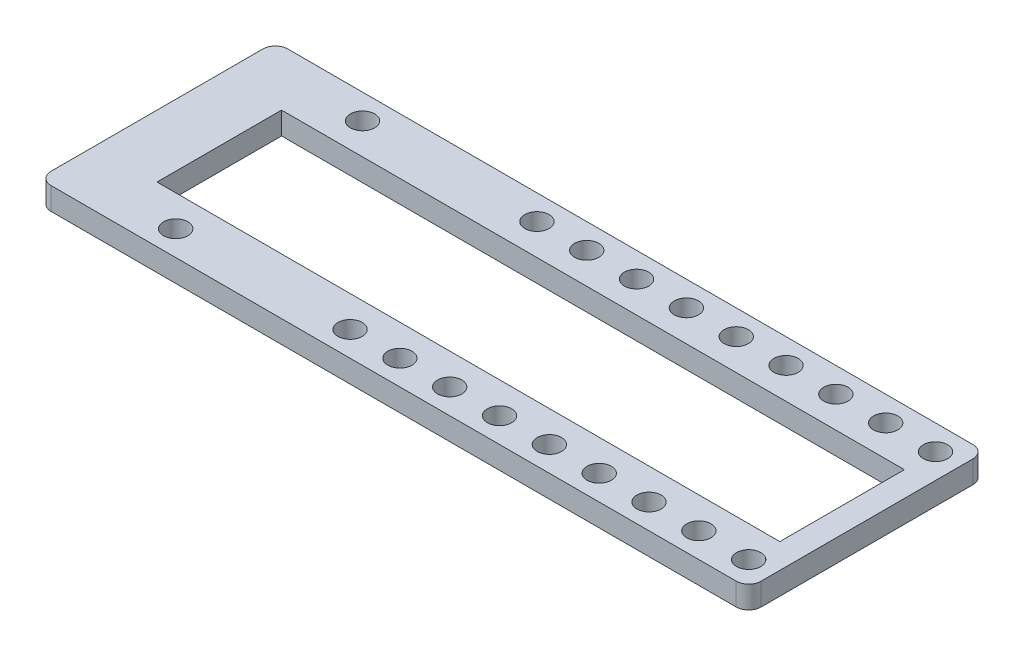
from build123d import *

# Parameters (mm, degrees)
BOSS_EXTRUDE1_DEPTH = 3.6
SKETCH2_R           = 1.95
SKETCH2_W           = 100
SKETCH2_H           = 20
CUT_EXTRUDE1_DEPTH  = 3.6


with BuildPart() as part:
    # Sketch1 → Boss-Extrude1 (new body)
    with BuildSketch(Plane(origin=(0, 0, 0), x_dir=(1, 0, 0), z_dir=(0, 1, 0))):
        with BuildLine():
            Line((2, 0), (112, 0))
            ThreePointArc((112, 0), (113.414213562, -0.585786438), (114, -2))
            Line((114, -2), (114, -36))
            ThreePointArc((114, -36), (113.414213562, -37.414213562), (112, -38))
            Line((112, -38), (2, -38))
            ThreePointArc((2, -38), (0.585786438, -37.414213562), (0, -36))
            Line((0, -36), (0, -2))
            ThreePointArc((0, -2), (0.585786438, -0.585786438), (2, 0))
        make_face()
    extrude(amount=BOSS_EXTRUDE1_DEPTH)

    # Sketch2 → Cut-Extrude1 (cut)
    with BuildSketch(Plane(origin=(0, 3.6, 0), x_dir=(1, 0, 0), z_dir=(0, 1, 0))):
        with Locations((110, -4)):
            Circle(SKETCH2_R)
        with Locations((102, -4)):
            Circle(SKETCH2_R)
        with Locations((18, -4)):
            Circle(SKETCH2_R)
        with Locations((46, -4)):
            Circle(SKETCH2_R)
        with Locations((54, -4)):
            Circle(SKETCH2_R)
        with Locations((62, -4)):
            Circle(SKETCH2_R)
        with Locations((70, -4)):
            Circle(SKETCH2_R)
        with Locations((78, -4)):
            Circle(SKETCH2_R)
        with Locations((86, -4)):
            Circle(SKETCH2_R)
        with Locations((94, -4)):
            Circle(SKETCH2_R)
        with Locations((110, -34)):
            Circle(SKETCH2_R)
        with Locations((102, -34)):
            Circle(SKETCH2_R)
        with Locations((18, -34)):
            Circle(SKETCH2_R)
        with Locations((46, -34)):
            Circle(SKETCH2_R)
        with Locations((54, -34)):
            Circle(SKETCH2_R)
        with Locations((62, -34)):
            Circle(SKETCH2_R)
        with Locations((70, -34)):
            Circle(SKETCH2_R)
        with Locations((78, -34)):
            Circle(SKETCH2_R)
        with Locations((86, -34)):
            Circle(SKETCH2_R)
        with Locations((94, -34)):
            Circle(SKETCH2_R)
        with Locations((60, -19)):
            Rectangle(SKETCH2_W, SKETCH2_H)
    extrude(amount=-CUT_EXTRUDE1_DEPTH, mode=Mode.SUBTRACT)


solid = part.part
